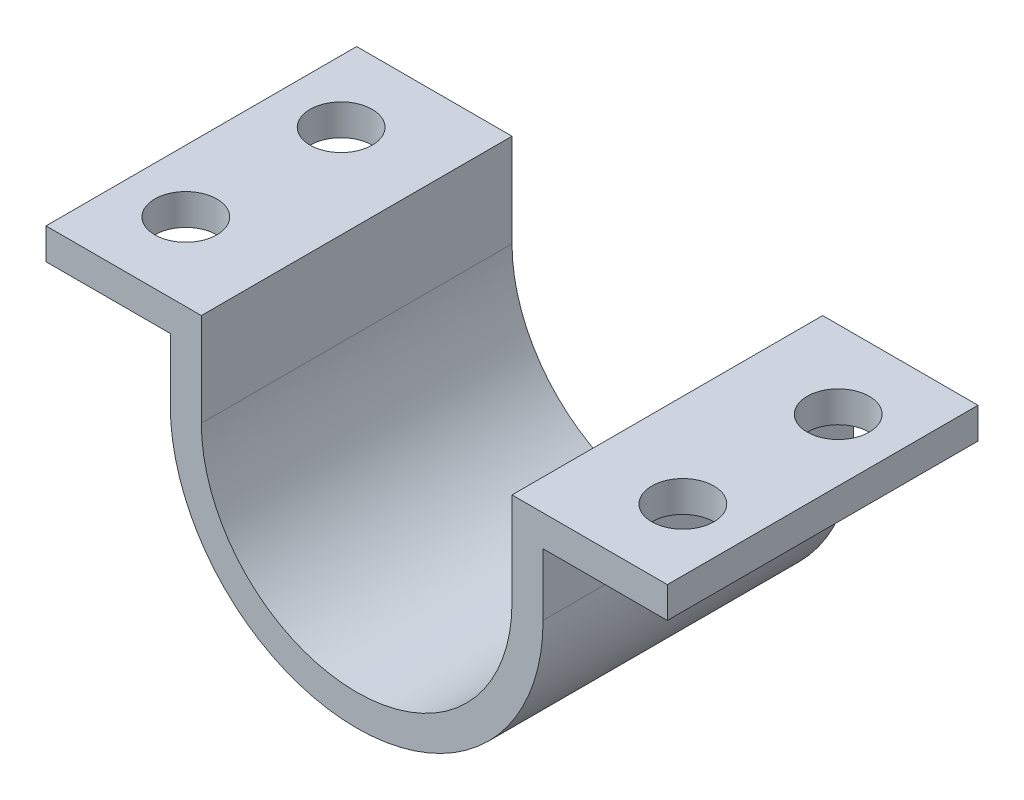
from build123d import *

# Parameters (mm, degrees)
BOSS_EXTRUDE1_DEPTH = 50
SKETCH2_R           = 5
CUT_EXTRUDE1_DEPTH  = 6


with BuildPart() as part:
    # Sketch1 → Boss-Extrude1 (new body)
    with BuildSketch(Plane.XY):
        with BuildLine():
            Line((-50, 15), (-25, 15))
            Line((-25, 15), (-25, 0))
            ThreePointArc((-25, 0), (0, -25), (25, 0))
            Line((25, 0), (25, 15))
            Line((25, 15), (50, 15))
            Line((50, 15), (50, 10))
            Line((50, 10), (30, 10))
            Line((30, 10), (30, 0))
            ThreePointArc((30, 0), (0, -30), (-30, 0))
            Line((-30, 0), (-30, 10))
            Line((-30, 10), (-50, 10))
            Line((-50, 10), (-50, 15))
        make_face()
    extrude(amount=BOSS_EXTRUDE1_DEPTH)

    # Sketch2 → Cut-Extrude1 (cut, through all)
    with BuildSketch(Plane.XZ.offset(-10)):
        with Locations((40, 37.5)):
            Circle(SKETCH2_R)
        with Locations((40, 12.5)):
            Circle(SKETCH2_R)
        with Locations((-40, 12.5)):
            Circle(SKETCH2_R)
        with Locations((-40, 37.5)):
            Circle(SKETCH2_R)
    extrude(amount=-CUT_EXTRUDE1_DEPTH, mode=Mode.SUBTRACT)


solid = part.part
